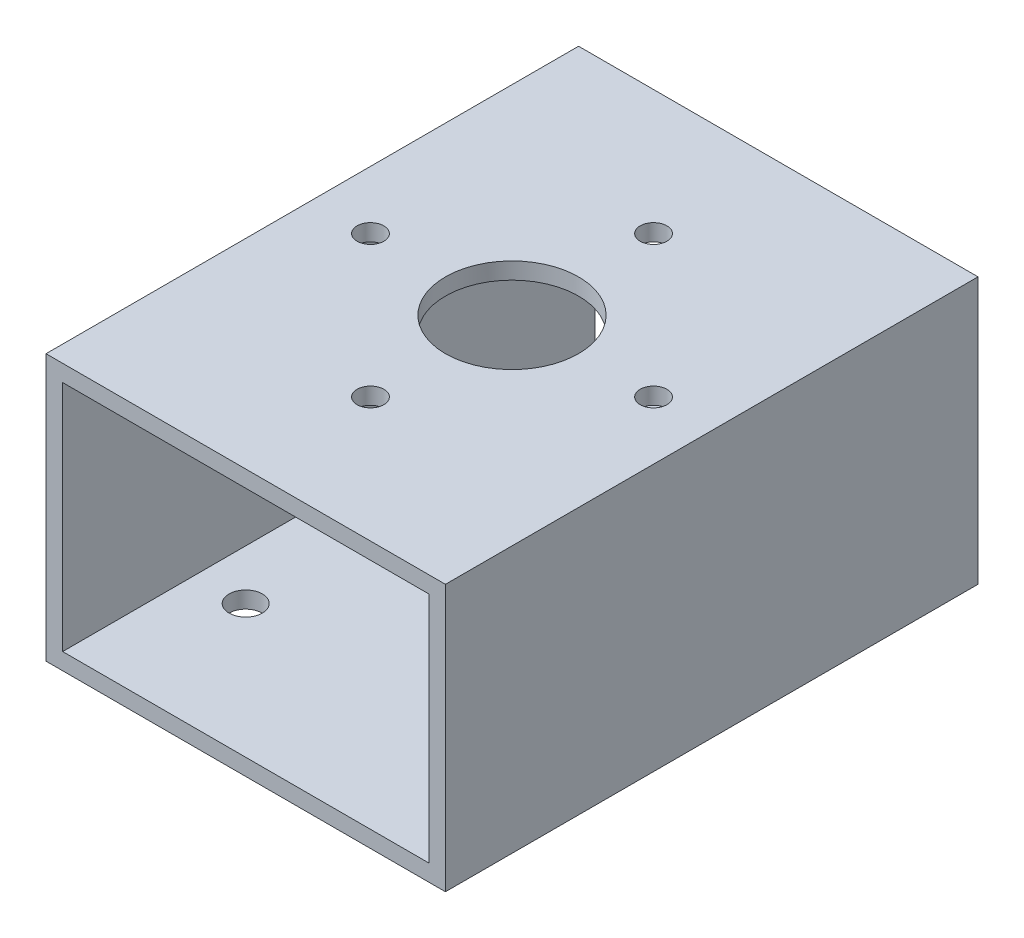
from build123d import *

# Parameters (mm, degrees)
SKETCH1_W                       = 76.2
SKETCH1_H                       = 50.8
SKETCH1_W_2                     = 69.85
SKETCH1_H_2                     = 44.45
BOSS_EXTRUDE1_DEPTH             = 101.6
F_7_0_201_DIAMETER_HOLE1_REACH  = 121.812
F_7_0_201_DIAMETER_HOLE1_BORE_R = 2.5527
F_1_4_0_25_DIAMETER_HOLE1_D     = 6.35
F_1_4_0_25_DIAMETER_HOLE1_DEPTH = 3.175
CUT_EXTRUDE1_REACH              = 121.812
SKETCH8_R                       = 12.7


with BuildPart() as part:
    # Sketch1 → Boss-Extrude1 (new body)
    with BuildSketch(Plane.XY):
        Rectangle(SKETCH1_W, SKETCH1_H)
        Rectangle(SKETCH1_W_2, SKETCH1_H_2, mode=Mode.SUBTRACT)
    extrude(amount=BOSS_EXTRUDE1_DEPTH)

    # #7 (0.201) Diameter Hole1 bore → #7 (0.201) Diameter Hole1 (cut, up to next)
    with BuildSketch(Plane(origin=(0, 25.4, 0), x_dir=(1, 0, 0), z_dir=(0, 1, 0)), mode=Mode.PRIVATE) as f_7_0_201_diameter_hole1_sk1:
        with Locations((-27.0002, -50.8)):
            Circle(F_7_0_201_DIAMETER_HOLE1_BORE_R)
    f_7_0_201_diameter_hole1_tool1 = extrude(f_7_0_201_diameter_hole1_sk1.sketch, amount=-F_7_0_201_DIAMETER_HOLE1_REACH, mode=Mode.PRIVATE) & part.part
    # #7 (0.201) Diameter Hole1 bore → #7 (0.201) Diameter Hole1 (cut, up to next)
    with BuildSketch(Plane(origin=(0, 25.4, 0), x_dir=(1, 0, 0), z_dir=(0, 1, 0)), mode=Mode.PRIVATE) as f_7_0_201_diameter_hole1_sk2:
        with Locations((0, -23.7998)):
            Circle(F_7_0_201_DIAMETER_HOLE1_BORE_R)
    f_7_0_201_diameter_hole1_tool2 = extrude(f_7_0_201_diameter_hole1_sk2.sketch, amount=-F_7_0_201_DIAMETER_HOLE1_REACH, mode=Mode.PRIVATE) & part.part
    # #7 (0.201) Diameter Hole1 bore → #7 (0.201) Diameter Hole1 (cut, up to next)
    with BuildSketch(Plane(origin=(0, 25.4, 0), x_dir=(1, 0, 0), z_dir=(0, 1, 0)), mode=Mode.PRIVATE) as f_7_0_201_diameter_hole1_sk3:
        with Locations((27.0002, -50.8)):
            Circle(F_7_0_201_DIAMETER_HOLE1_BORE_R)
    f_7_0_201_diameter_hole1_tool3 = extrude(f_7_0_201_diameter_hole1_sk3.sketch, amount=-F_7_0_201_DIAMETER_HOLE1_REACH, mode=Mode.PRIVATE) & part.part
    # #7 (0.201) Diameter Hole1 bore → #7 (0.201) Diameter Hole1 (cut, up to next)
    with BuildSketch(Plane(origin=(0, 25.4, 0), x_dir=(1, 0, 0), z_dir=(0, 1, 0)), mode=Mode.PRIVATE) as f_7_0_201_diameter_hole1_sk4:
        with Locations((0, -77.8002)):
            Circle(F_7_0_201_DIAMETER_HOLE1_BORE_R)
    f_7_0_201_diameter_hole1_tool4 = extrude(f_7_0_201_diameter_hole1_sk4.sketch, amount=-F_7_0_201_DIAMETER_HOLE1_REACH, mode=Mode.PRIVATE) & part.part
    add(f_7_0_201_diameter_hole1_tool1.solids().sort_by_distance((-27.0002, 25.4, 50.8))[0], mode=Mode.SUBTRACT)
    add(f_7_0_201_diameter_hole1_tool2.solids().sort_by_distance((0, 25.4, 23.7998))[0], mode=Mode.SUBTRACT)
    add(f_7_0_201_diameter_hole1_tool3.solids().sort_by_distance((27.0002, 25.4, 50.8))[0], mode=Mode.SUBTRACT)
    add(f_7_0_201_diameter_hole1_tool4.solids().sort_by_distance((0, 25.4, 77.8002))[0], mode=Mode.SUBTRACT)

    # 1/4 (0.25) Diameter Hole1
    with Locations(Plane(origin=(0, -25.4, 0), x_dir=(-1, 0, 0), z_dir=(0, -1, 0))):
        with Locations((25.4, -25.4), (25.4, -76.2), (-25.4, -76.2), (-25.4, -25.4)):
            Hole(F_1_4_0_25_DIAMETER_HOLE1_D / 2, depth=F_1_4_0_25_DIAMETER_HOLE1_DEPTH)

    # Sketch8 → Cut-Extrude1 (cut, up to next)
    with BuildSketch(Plane(origin=(0, 25.4, 0), x_dir=(1, 0, 0), z_dir=(0, 1, 0)), mode=Mode.PRIVATE) as cut_extrude1_sk1:
        with Locations(Location((0, -50.8, 0), (0, 0, 270))):
            Circle(SKETCH8_R)
    cut_extrude1_tool1 = extrude(cut_extrude1_sk1.sketch, amount=-CUT_EXTRUDE1_REACH, mode=Mode.PRIVATE) & part.part
    add(cut_extrude1_tool1.solids().sort_by_distance((0, 25.4, 50.8))[0], mode=Mode.SUBTRACT)


solid = part.part
